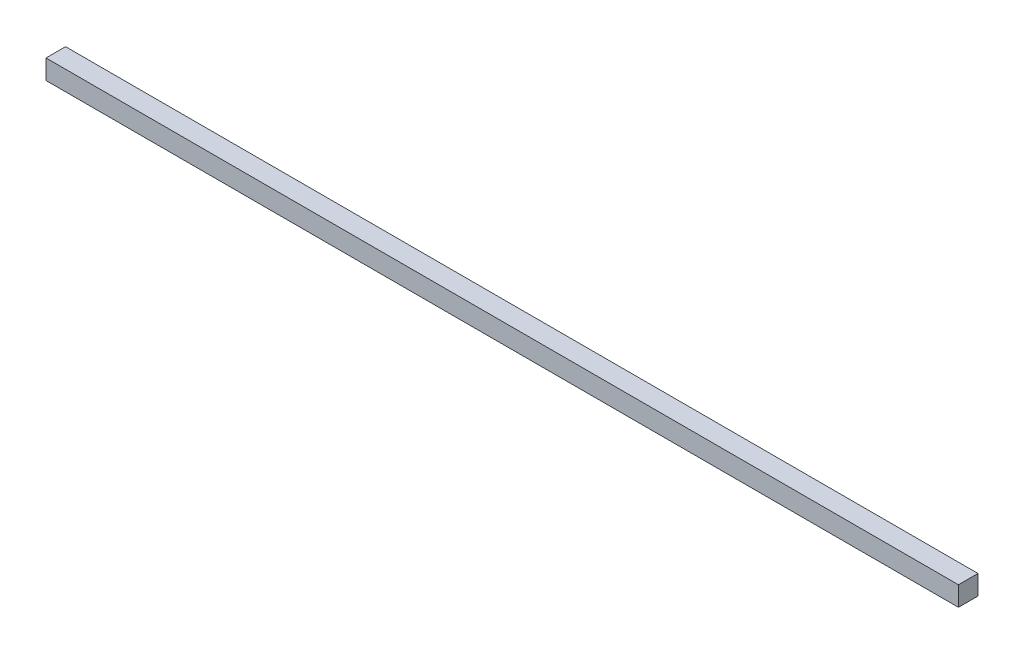
from build123d import *

# Parameters (mm, degrees)
SKETCH1_W           = 15
SKETCH1_H           = 15
BOSS_EXTRUDE1_DEPTH = 700


with BuildPart() as part:
    # Sketch1 → Boss-Extrude1 (new body)
    with BuildSketch(Plane(origin=(0, 0, 0), x_dir=(0, 0, -1), z_dir=(1, 0, 0))):
        with Locations((7.5, 7.5)):
            Rectangle(SKETCH1_W, SKETCH1_H)
    extrude(amount=BOSS_EXTRUDE1_DEPTH)


solid = part.part
